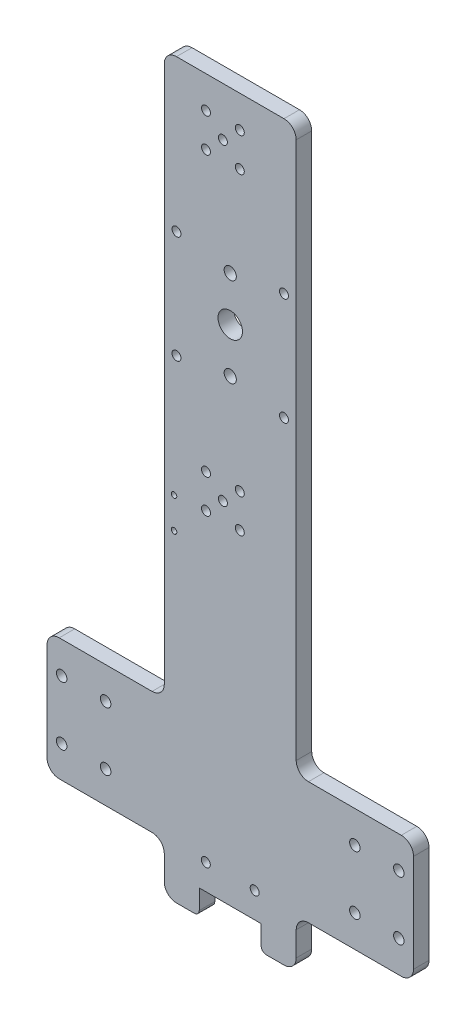
from build123d import *

# Parameters (mm, degrees)
BOSS_EXTRUDE1_DEPTH           = 6.35
FILLET1_R                     = 5
SKETCH3_R                     = 5
CUT_EXTRUDE1_DEPTH            = 7.35
F_6_CLEARANCE_HOLE1_D         = 3.6576
CUT_EXTRUDE2_DEPTH            = 7.35
F_10_CLEARANCE_HOLE2_D        = 4.9784
F_6_CLEARANCE_HOLE2_D         = 3.6576
F_8_CLEARANCE_HOLE1_D         = 4.3053
TAP_DRILL_FOR_4_40_TAP1_D     = 2.2606
TAP_DRILL_FOR_4_40_TAP1_DEPTH = 6.35
TAP_DRILL_FOR_4_40_TAP1_TIP   = 0.679152758
FILLET2_R                     = 2


with BuildPart() as part:
    # Sketch1 → Boss-Extrude1 (new body)
    with BuildSketch(Plane.XY):
        Polygon((-27, 70), (-27, 300), (27, 300), (27, 70), (75, 70), (75, 20), (27, 20), (27, 0), (-27, 0), (-27, 20), (-75, 20), (-75, 70), align=None)
    extrude(amount=BOSS_EXTRUDE1_DEPTH)

    # Fillet1
    fillet1_edges = [part.edges().sort_by_distance(p)[0] for p in [
        (-75, 70, 3.175),
        (-27, 70, 3.175),
        (-27, 300, 3.175),
        (27, 300, 3.175),
        (27, 70, 3.175),
        (75, 70, 3.175),
        (75, 20, 3.175),
        (27, 20, 3.175),
        (27, 0, 3.175),
        (-27, 0, 3.175),
        (-27, 20, 3.175),
        (-75, 20, 3.175),
    ]]
    fillet(fillet1_edges, radius=FILLET1_R)

    # Sketch3 → Cut-Extrude1 (cut, through all)
    with BuildSketch(Plane.XY.offset(6.35)):
        with Locations((0, 216)):
            Circle(SKETCH3_R)
    extrude(amount=-CUT_EXTRUDE1_DEPTH, mode=Mode.SUBTRACT)

    # #6 Clearance Hole1 (through all)
    with Locations(Plane.XY.offset(6.35)):
        with Locations((-22, 238), (-22, 194), (22, 194), (22, 238), (-9.914797213, 273.085202787), (-9.914797213, 286.914797213), (3.914797213, 286.914797213), (3.914797213, 273.085202787), (-9.914797213, 158.914797213), (3.914797213, 158.914797213), (3.914797213, 145.085202787), (-9.914797213, 145.085202787), (-3, 280), (-3, 152)):
            Hole(F_6_CLEARANCE_HOLE1_D / 2)

    # Sketch6 → Cut-Extrude2 (cut, through all)
    with BuildSketch(Plane.XY.offset(6.35)):
        Polygon((-12.7, 0), (-12.6, 10), (12.6, 10), (12.7, 0), align=None)
    extrude(amount=-CUT_EXTRUDE2_DEPTH, mode=Mode.SUBTRACT)

    # #10 Clearance Hole2 (through all)
    with Locations(Plane.XY.offset(6.35)):
        with Locations((0, 197.75), (0, 234.25)):
            Hole(F_10_CLEARANCE_HOLE2_D / 2)

    # #6 Clearance Hole2 (through all)
    with Locations(Plane(origin=(-10, 20.4648, 6.35), x_dir=(1, 0, 0), z_dir=(0, 0, 1))):
        with Locations((0, 0), (20, 0)):
            Hole(F_6_CLEARANCE_HOLE2_D / 2)

    # #8 Clearance Hole1 (through all)
    with Locations(Plane(origin=(51, 57, 6.35), x_dir=(1, 0, 0), z_dir=(0, 0, 1))):
        with Locations((0, 0), (18, 0), (18, -24), (0, -24), (-102, 0), (-120, 0), (-120, -24), (-102, -24)):
            Hole(F_8_CLEARANCE_HOLE1_D / 2)

    # Tap Drill for #4-40 Tap1
    with Locations(Plane(origin=(-23, 131.426, 6.35), x_dir=(1, 0, 0), z_dir=(0, 0, 1))):
        with Locations((0, 0), (0, 12.7)):
            Hole(TAP_DRILL_FOR_4_40_TAP1_D / 2, depth=TAP_DRILL_FOR_4_40_TAP1_DEPTH)
            with Locations((0, 0, -(TAP_DRILL_FOR_4_40_TAP1_DEPTH + TAP_DRILL_FOR_4_40_TAP1_TIP / 2))):  # 118° drill point
                Cone(0, TAP_DRILL_FOR_4_40_TAP1_D / 2, TAP_DRILL_FOR_4_40_TAP1_TIP, mode=Mode.SUBTRACT)

    # Fillet2
    fillet2_edges = [part.edges().sort_by_distance(p)[0] for p in [
        (12.7, 0, 3.175),
        (-12.7, 0, 3.175),
    ]]
    fillet(fillet2_edges, radius=FILLET2_R)


solid = part.part
